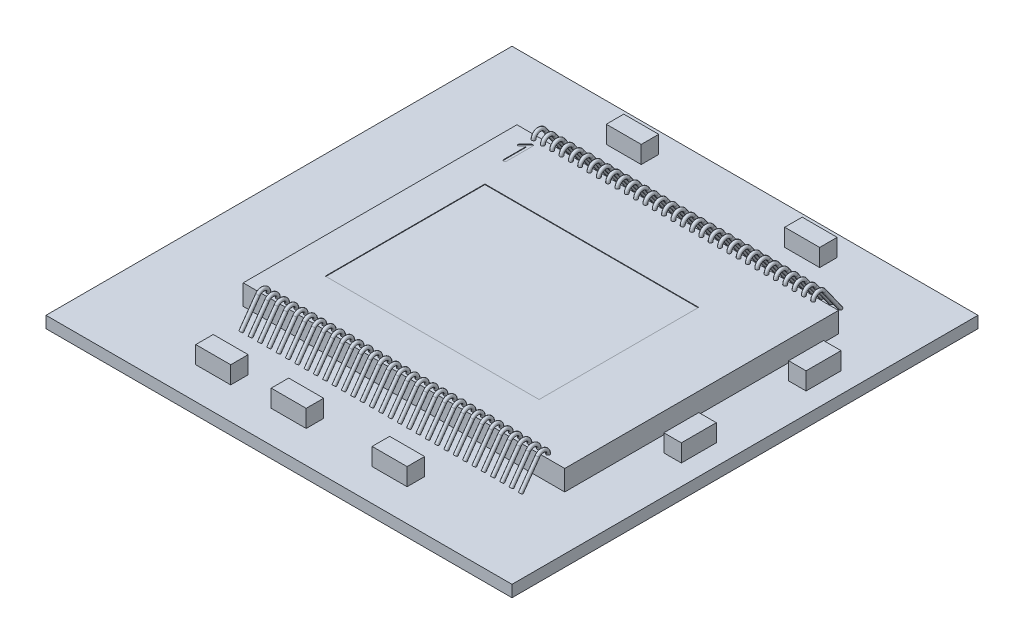
from build123d import *

# Parameters (mm, degrees)
SKIZZE1_W                   = 5.52
SKIZZE1_H                   = 4.7
CHIP_DIE_DEPTH              = 0.35
SKIZZE4_W                   = 3.67
SKIZZE4_H                   = 2.74
ACTIVE_AREA_DEPTH           = 0.01
PIN1_DEPTH                  = 0.01
SKIZZE6_W                   = 8
SKIZZE6_H                   = 8
BASE_PLATE_DEPTH            = 0.2
SKIZZE13_R                  = 0.03
SKIZZE14_W                  = 0.6
SKIZZE14_H                  = 0.3
SKIZZE14_W_2                = 0.3
SKIZZE14_H_2                = 0.6
ELECTRONIC_COMPONENTS_DEPTH = 0.3


with BuildPart() as part:
    # Skizze1 → Chip_Die (new body)
    with BuildSketch(Plane(origin=(0, 0, 0), x_dir=(1, 0, 0), z_dir=(0, 1, 0))):
        Rectangle(SKIZZE1_W, SKIZZE1_H)
    extrude(amount=CHIP_DIE_DEPTH)

    # Skizze4 → Active_Area (cut)
    with BuildSketch(Plane(origin=(0, 0.35, 0), x_dir=(1, 0, 0), z_dir=(0, 1, 0))):
        with Locations((-0.32, -0.175)):
            Rectangle(SKIZZE4_W, SKIZZE4_H)
    extrude(amount=-ACTIVE_AREA_DEPTH, mode=Mode.SUBTRACT)

    # Skizze5 → Pin1 (cut)
    with BuildSketch(Plane(origin=(0, 0.35, 0), x_dir=(1, 0, 0), z_dir=(0, 1, 0))):
        with BuildLine():
            Line((-2.357101993, 2.106176307), (-2.414356458, 2.048921843))
            add(Edge.make_bspline(
                [(-2.414356458, 2.048921843), (-2.41558148, 2.047825919), (-2.41797629, 2.045683486), (-2.422242966, 2.043408791), (-2.426881736, 2.042023199), (-2.430120538, 2.041861298), (-2.431767172, 2.041778986)],
                knots=[0, 0, 0, 0, 1.018353941, 1.990791669, 2.978501366, 4, 4, 4, 4], degree=3))
            add(Edge.make_bspline(
                [(-2.431767172, 2.041778986), (-2.433711964, 2.041810316), (-2.437386426, 2.041869511), (-2.442458748, 2.043177127), (-2.446899665, 2.045001386), (-2.4503836, 2.047939343), (-2.453321557, 2.051423278), (-2.455145817, 2.055864195), (-2.456453432, 2.060936517), (-2.456512627, 2.064610979), (-2.456543958, 2.066555771)],
                knots=[0, 0, 0, 0, 1.158343618, 2.188557439, 3.114345967, 4, 4.885654033, 5.811442561, 6.841656382, 8, 8, 8, 8], degree=3))
            add(Edge.make_bspline(
                [(-2.456543958, 2.066555771), (-2.456461646, 2.068202406), (-2.456299744, 2.071441208), (-2.454914152, 2.076079977), (-2.452639457, 2.080346653), (-2.450497024, 2.082741463), (-2.449401101, 2.083966486)],
                knots=[0, 0, 0, 0, 1.021498634, 2.009208331, 2.981646059, 4, 4, 4, 4], degree=3))
            Line((-2.449401101, 2.083966486), (-2.352191279, 2.181622736))
            add(Edge.make_bspline(
                [(-2.352191279, 2.181622736), (-2.350611043, 2.18314872), (-2.347620367, 2.186036721), (-2.342464678, 2.189017516), (-2.337365943, 2.191171267), (-2.333833774, 2.191354384), (-2.332101993, 2.191444164)],
                knots=[0, 0, 0, 0, 1.143618958, 2.164355411, 3.100005221, 4, 4, 4, 4], degree=3))
            add(Edge.make_bspline(
                [(-2.332101993, 2.191444164), (-2.330118795, 2.191417626), (-2.326404942, 2.19136793), (-2.321274026, 2.19001897), (-2.316766965, 2.18825574), (-2.313266562, 2.185279596), (-2.310290418, 2.181779193), (-2.308527187, 2.177272132), (-2.307178228, 2.172141215), (-2.307128531, 2.168427362), (-2.307101993, 2.166444164)],
                knots=[0, 0, 0, 0, 1.168121455, 2.187492668, 3.123667138, 4, 4.876332862, 5.812507332, 6.831878545, 8, 8, 8, 8], degree=3))
            Line((-2.307101993, 2.166444164), (-2.307101993, 1.716444164))
            add(Edge.make_bspline(
                [(-2.307101993, 1.716444164), (-2.307138501, 1.714501184), (-2.307208159, 1.710793888), (-2.308470805, 1.705664739), (-2.310366712, 1.701200671), (-2.313182372, 1.697592478), (-2.316843288, 1.694796894), (-2.321218561, 1.692790376), (-2.326434692, 1.691712558), (-2.330125466, 1.691537769), (-2.332101993, 1.691444164)],
                knots=[0, 0, 0, 0, 1.147825403, 2.190104258, 3.107486261, 4.002358969, 4.866307497, 5.812869616, 6.828721528, 8, 8, 8, 8], degree=3))
            add(Edge.make_bspline(
                [(-2.332101993, 1.691444164), (-2.334038545, 1.69154681), (-2.337723047, 1.691742105), (-2.342937502, 1.692733919), (-2.347269511, 1.694873505), (-2.351037696, 1.697508461), (-2.353672652, 1.701276646), (-2.355812239, 1.705608656), (-2.356804052, 1.71082311), (-2.356999348, 1.714507613), (-2.357101993, 1.716444164)],
                knots=[0, 0, 0, 0, 1.150813752, 2.189550435, 3.117366144, 4, 4.882633856, 5.810449565, 6.849186248, 8, 8, 8, 8], degree=3))
            Line((-2.357101993, 1.716444164), (-2.357101993, 2.106176307))
        make_face()
    extrude(amount=-PIN1_DEPTH, mode=Mode.SUBTRACT)

    # Skizze6 → Base-Plate (add)
    with BuildSketch(Plane(origin=(0, 0, 0), x_dir=(1, 0, 0), z_dir=(0, 1, 0))):
        with Locations((-0.32, -0.175)):
            Rectangle(SKIZZE6_W, SKIZZE6_H)
    extrude(amount=-BASE_PLATE_DEPTH)

    # Bonding-wires: sweep along a path in Skizze12
    with BuildLine(Plane(origin=(0, 0, 0), x_dir=(0, 0, -1), z_dir=(1, 0, 0))) as bonding_wires_path:
        Line((-2.745842332, 0), (-2.456320682, 0.407882256))
        ThreePointArc((-2.456320682, 0.407882256), (-2.34439882, 0.445274696), (-2.27477533, 0.35))
    # Skizze13 → Bonding-wires (sweep)
    with BuildSketch(Plane(origin=(0, 0.35, 0), x_dir=(1, 0, 0), z_dir=(0, 1, 0))):
        with Locations((0, -2.27477533)):
            Circle(SKIZZE13_R)
        with Locations((0.16, -2.27477533)):
            Circle(SKIZZE13_R)
        with Locations((0.32, -2.27477533)):
            Circle(SKIZZE13_R)
        with Locations((0.48, -2.27477533)):
            Circle(SKIZZE13_R)
        with Locations((0.64, -2.27477533)):
            Circle(SKIZZE13_R)
        with Locations((0.8, -2.27477533)):
            Circle(SKIZZE13_R)
        with Locations((0.96, -2.27477533)):
            Circle(SKIZZE13_R)
        with Locations((1.12, -2.27477533)):
            Circle(SKIZZE13_R)
        with Locations((1.28, -2.27477533)):
            Circle(SKIZZE13_R)
        with Locations((1.44, -2.27477533)):
            Circle(SKIZZE13_R)
        with Locations((1.6, -2.27477533)):
            Circle(SKIZZE13_R)
        with Locations((1.76, -2.27477533)):
            Circle(SKIZZE13_R)
        with Locations((1.92, -2.27477533)):
            Circle(SKIZZE13_R)
        with Locations((2.08, -2.27477533)):
            Circle(SKIZZE13_R)
        with Locations((2.24, -2.27477533)):
            Circle(SKIZZE13_R)
        with Locations((2.4, -2.27477533)):
            Circle(SKIZZE13_R)
        with Locations((-2.4, -2.27477533)):
            Circle(SKIZZE13_R)
        with Locations((-2.24, -2.27477533)):
            Circle(SKIZZE13_R)
        with Locations((-2.08, -2.27477533)):
            Circle(SKIZZE13_R)
        with Locations((-1.92, -2.27477533)):
            Circle(SKIZZE13_R)
        with Locations((-1.76, -2.27477533)):
            Circle(SKIZZE13_R)
        with Locations((-1.6, -2.27477533)):
            Circle(SKIZZE13_R)
        with Locations((-1.44, -2.27477533)):
            Circle(SKIZZE13_R)
        with Locations((-1.28, -2.27477533)):
            Circle(SKIZZE13_R)
        with Locations((-1.12, -2.27477533)):
            Circle(SKIZZE13_R)
        with Locations((-0.96, -2.27477533)):
            Circle(SKIZZE13_R)
        with Locations((-0.8, -2.27477533)):
            Circle(SKIZZE13_R)
        with Locations((-0.64, -2.27477533)):
            Circle(SKIZZE13_R)
        with Locations((-0.48, -2.27477533)):
            Circle(SKIZZE13_R)
        with Locations((-0.32, -2.27477533)):
            Circle(SKIZZE13_R)
        with Locations((-0.16, -2.27477533)):
            Circle(SKIZZE13_R)
    bonding_wires = sweep(path=bonding_wires_path.line)

    # Spiegeln1: Bonding-wires across plane
    add(bonding_wires.mirror(Plane.XY))

    # Skizze14 → Electronic_components (add)
    with BuildSketch(Plane(origin=(0, 0, 0), x_dir=(1, 0, 0), z_dir=(0, 1, 0))):
        with Locations((-1.999418048, -3.475)):
            Rectangle(SKIZZE14_W, SKIZZE14_H)
        with Locations((-0.703560794, -3.475)):
            Rectangle(SKIZZE14_W, SKIZZE14_H)
        with Locations((1.029102277, -3.475)):
            Rectangle(SKIZZE14_W, SKIZZE14_H)
        with Locations((3.18, -0.61809576)):
            Rectangle(SKIZZE14_W_2, SKIZZE14_H_2)
        with Locations((3.18, 1.52363245)):
            Rectangle(SKIZZE14_W_2, SKIZZE14_H_2)
        with Locations((-1.75145144, 3.325)):
            Rectangle(SKIZZE14_W, SKIZZE14_H)
        with Locations((1.311955252, 3.325)):
            Rectangle(SKIZZE14_W, SKIZZE14_H)
    extrude(amount=ELECTRONIC_COMPONENTS_DEPTH)


solid = part.part
